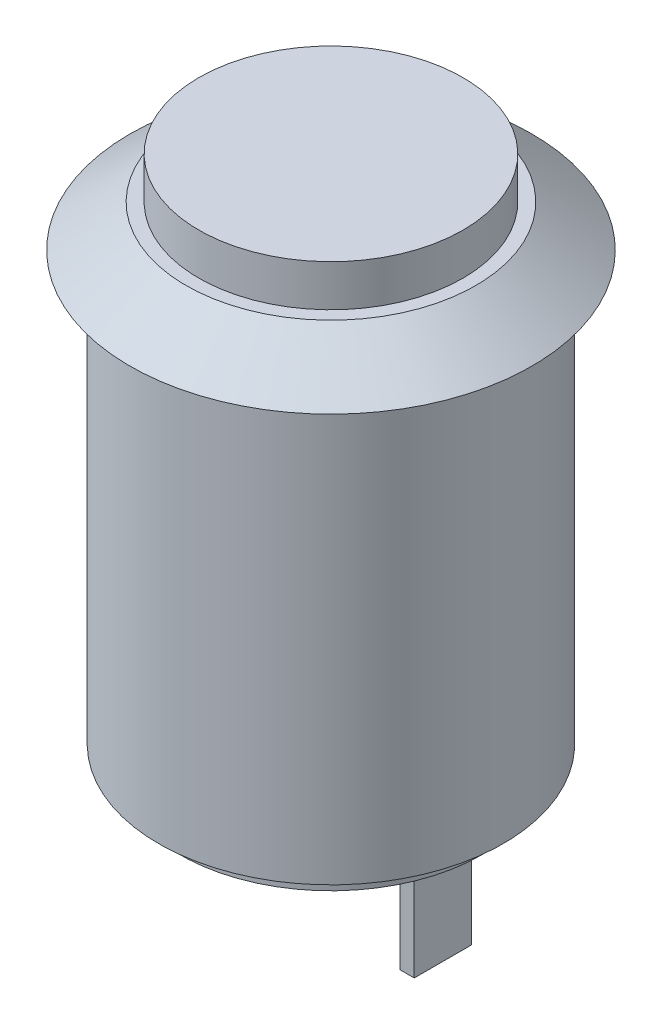
from build123d import *

# Parameters (mm, degrees)
SKETCH2_R           = 5.264069535
BOSS_EXTRUDE1_DEPTH = 0.7
SKETCH3_W           = 0.5
SKETCH3_H           = 2
BOSS_EXTRUDE2_DEPTH = 3.9


with BuildPart() as part:
    # Sketch1 → Revolve1 (revolve)
    with BuildSketch(Plane.XY):
        Polygon((0, -14.9), (6, -14.9), (6, 0), (7, 0), (5.043279744, 1.45), (4.6, 1.45), (4.6, 2.9), (0, 2.9), align=None)
    revolve(axis=Axis((0, 2.9, 0), (0, -1, 0)))

    # Sketch2 → Boss-Extrude1 (add)
    with BuildSketch(Plane.XZ.offset(14.9)):
        Circle(SKETCH2_R)
    extrude(amount=BOSS_EXTRUDE1_DEPTH)

    # Sketch3 → Boss-Extrude2 (add)
    with BuildSketch(Plane.XZ.offset(15.6)):
        with Locations((-3.65, 0)):
            Rectangle(SKETCH3_W, SKETCH3_H)
        with Locations((3.65, 0)):
            Rectangle(SKETCH3_W, SKETCH3_H)
    extrude(amount=BOSS_EXTRUDE2_DEPTH)


solid = part.part
